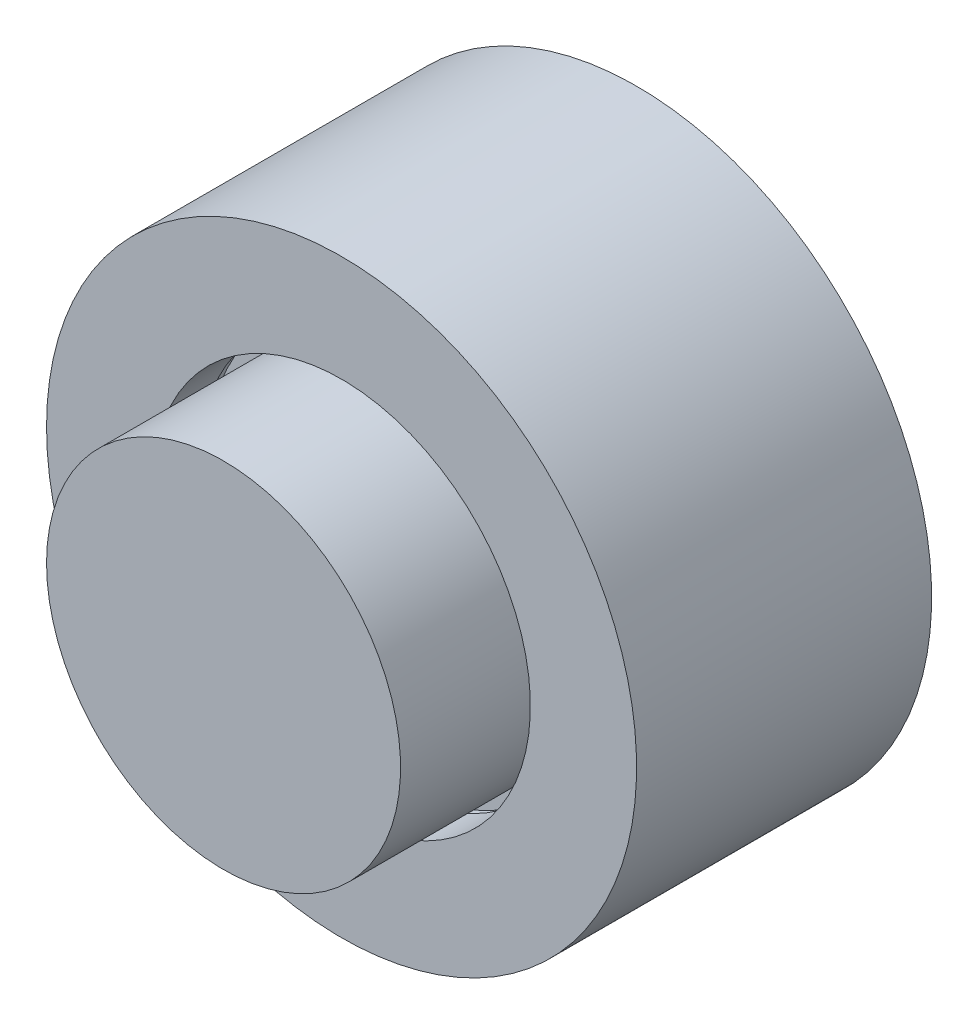
from build123d import *


with BuildPart() as part:
    # Sketch3 → Revolve3 (revolve)
    with BuildSketch(Plane(origin=(0, 0, 0), x_dir=(1, 0, 0), z_dir=(0, 1, 0))):
        Polygon((0, 1), (0, 0), (3, 0), (3, 3), (3.25, 3), (3.25, 4), (1.5, 4), (1.5, 1), align=None)
    revolve(axis=Axis((0, 0, 0), (0, 0, 1)))


with BuildPart() as body_2:
    # Sketch3_3 → Revolve4 (revolve)
    with BuildSketch(Plane(origin=(0, 0, 0), x_dir=(1, 0, 0), z_dir=(0, 1, 0))):
        Polygon((0, 7), (0, 6), (3.45, 6), (3.45, 2.8), (3.2, 2.8), (3.2, 2), (5, 2), (5, 7), align=None)
    revolve(axis=Axis((0, 0, 0), (0, 0, 1)))


solid = Compound([part.part, body_2.part])
